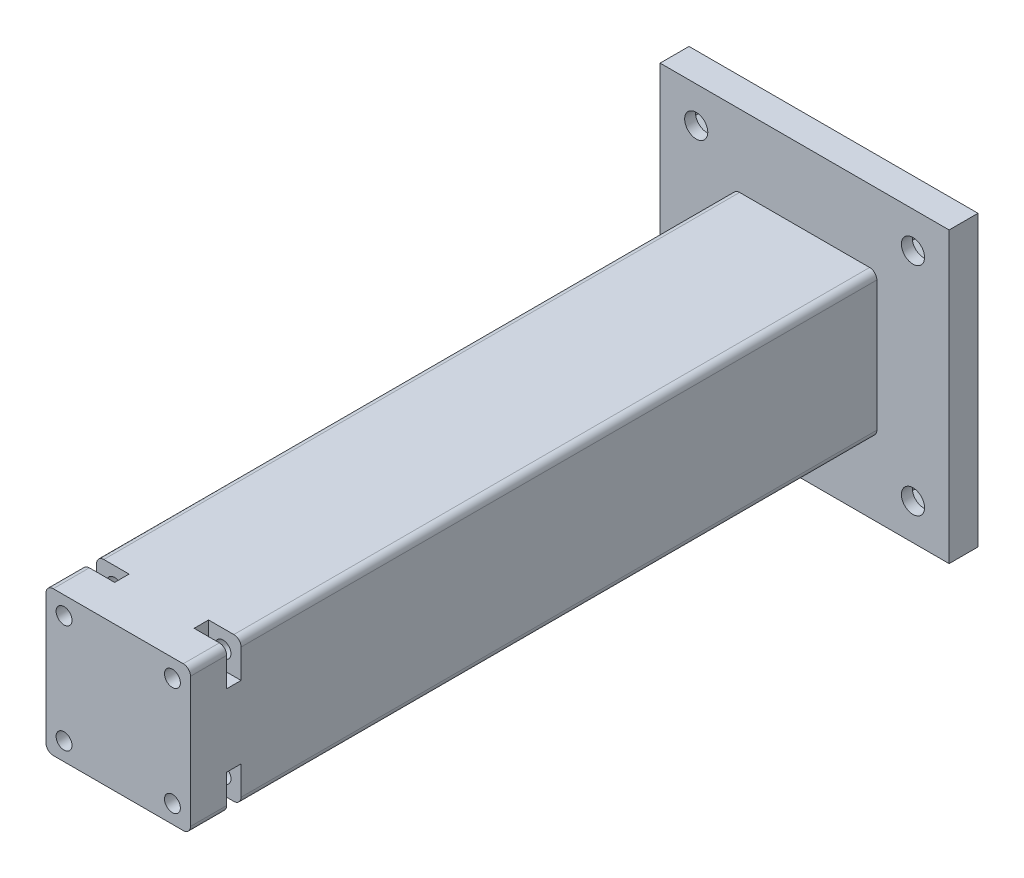
from build123d import *

# Parameters (mm, degrees)
ESQUISSE1_W             = 40
ESQUISSE1_H             = 40
BOSS_EXTRU_1_DEPTH      = 4
ESQUISSE4_W             = 20
ESQUISSE4_H             = 20
BOSS_EXTRU_4_DEPTH      = 95
CONG_3_R                = 1
ESQUISSE5_R             = 1.1
ENL_V_MAT_EXTRU_1_DEPTH = 20
ESQUISSE6_W             = 4.5
ESQUISSE6_H             = 2
ENL_V_MAT_EXTRU_2_DEPTH = 5
ESQUISSE7_R             = 1.6
ENL_V_MAT_EXTRU_3_DEPTH = 4
ENL_V_MAT_EXTRU_4_DEPTH = 2.5


with BuildPart() as part:
    # Esquisse1 → Boss.-Extru.1 (new body)
    with BuildSketch(Plane.XY):
        Rectangle(ESQUISSE1_W, ESQUISSE1_H)
    extrude(amount=BOSS_EXTRU_1_DEPTH)

    # Esquisse4 → Boss.-Extru.4 (add)
    with BuildSketch(Plane.XY.offset(4)):
        Rectangle(ESQUISSE4_W, ESQUISSE4_H)
    extrude(amount=BOSS_EXTRU_4_DEPTH)

    # Congé3
    cong_3_edges = [part.edges().sort_by_distance(p)[0] for p in [
        (-10, 10, 51.5),
        (-10, -10, 51.5),
        (10, -10, 51.5),
        (10, 10, 51.5),
    ]]
    fillet(cong_3_edges, radius=CONG_3_R)

    # Esquisse5 → Enlèv. mat.-Extru.1 (cut)
    with BuildSketch(Plane.XY.offset(99)):
        with Locations((7.5, 7.5)):
            Circle(ESQUISSE5_R)
        with Locations((-7.5, 7.5)):
            Circle(ESQUISSE5_R)
        with Locations((-7.5, -7.5)):
            Circle(ESQUISSE5_R)
        with Locations((7.5, -7.5)):
            Circle(ESQUISSE5_R)
    extrude(amount=-ENL_V_MAT_EXTRU_1_DEPTH, mode=Mode.SUBTRACT)

    # Esquisse6 → Enlèv. mat.-Extru.2 (cut)
    with BuildSketch(Plane.XZ.offset(10)):
        with Locations((-7.75, 93)):
            Rectangle(ESQUISSE6_W, ESQUISSE6_H)
        with Locations((7.75, 93)):
            Rectangle(ESQUISSE6_W, ESQUISSE6_H)
    enl_v_mat_extru_2 = extrude(amount=-ENL_V_MAT_EXTRU_2_DEPTH, mode=Mode.SUBTRACT)

    # Symétrie1: Enlèv. mat.-Extru.2 across plane
    add(enl_v_mat_extru_2.mirror(Plane.ZX), mode=Mode.SUBTRACT)

    # Esquisse7 → Enlèv. mat.-Extru.3 (cut)
    with BuildSketch(Plane(origin=(0, 0, 0), x_dir=(-1, 0, 0), z_dir=(0, 0, -1))):
        with Locations((15, 15)):
            Circle(ESQUISSE7_R)
        with Locations((15, -15)):
            Circle(ESQUISSE7_R)
        with Locations((-15, -15)):
            Circle(ESQUISSE7_R)
        with Locations((-15, 15)):
            Circle(ESQUISSE7_R)
    extrude(amount=-ENL_V_MAT_EXTRU_3_DEPTH, mode=Mode.SUBTRACT)

    # Esquisse8 → Enlèv. mat.-Extru.4 (cut)
    with BuildSketch(Plane(origin=(0, 0, 0), x_dir=(-1, 0, 0), z_dir=(0, 0, -1))):
        Polygon((-11.968911087, 13.25), (-11.968911087, 16.75), (-15, 18.5), (-18.031088913, 16.75), (-18.031088913, 13.25), (-15, 11.5), align=None)
        Polygon((15, 11.5), (18.031088913, 13.25), (18.031088913, 16.75), (15, 18.5), (11.968911087, 16.75), (11.968911087, 13.25), align=None)
        Polygon((15, -18.5), (18.031088913, -16.75), (18.031088913, -13.25), (15, -11.5), (11.968911087, -13.25), (11.968911087, -16.75), align=None)
        Polygon((-11.968911087, -16.75), (-11.968911087, -13.25), (-15, -11.5), (-18.031088913, -13.25), (-18.031088913, -16.75), (-15, -18.5), align=None)
    extrude(amount=-ENL_V_MAT_EXTRU_4_DEPTH, mode=Mode.SUBTRACT)


solid = part.part
